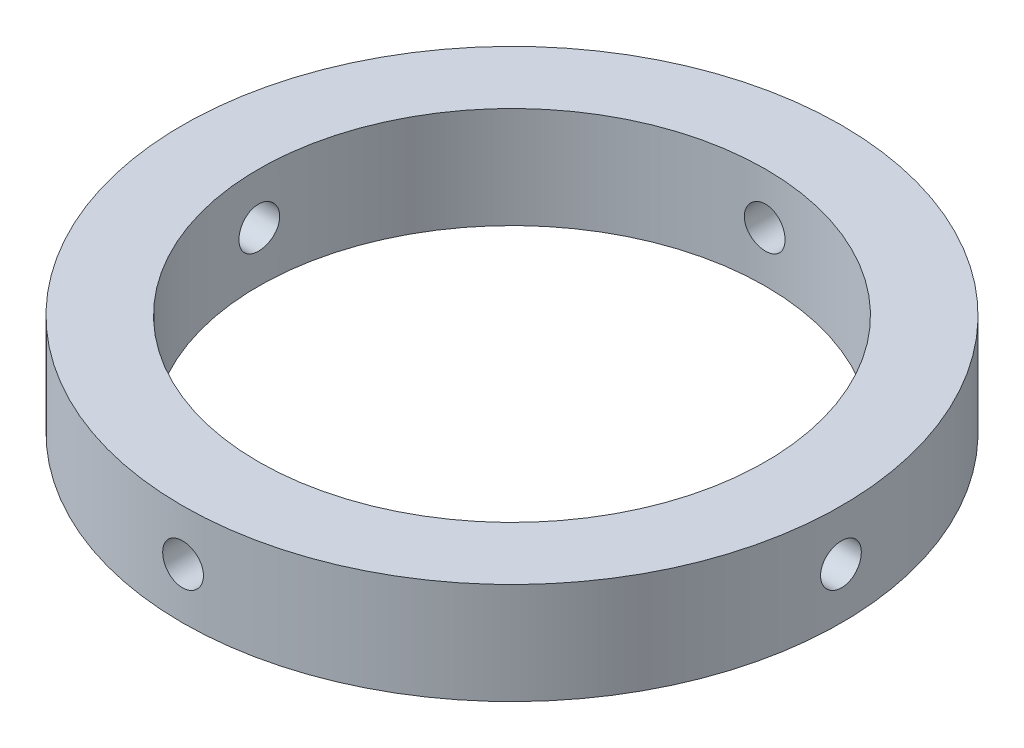
from build123d import *

# Parameters (mm, degrees)
SKETCH1_R           = 41.275
SKETCH1_R_2         = 31.75
BOSS_EXTRUDE1_DEPTH = 12.7
CIRPATTERN1_COUNT   = 4


with BuildPart() as part:
    # Sketch1 → Boss-Extrude1 (new body)
    with BuildSketch(Plane(origin=(0, 0, 0), x_dir=(1, 0, 0), z_dir=(0, 1, 0))):
        Circle(SKETCH1_R)
        Circle(SKETCH1_R_2, mode=Mode.SUBTRACT)
    extrude(amount=BOSS_EXTRUDE1_DEPTH)

    # Sketch3 → 7 _0.201_ Diameter Hole1 (revolve, cut)
    with BuildSketch(Plane(origin=(0, 6.35, 41.275), x_dir=(0, -1, 0), z_dir=(1, 0, 0))):
        Polygon((0, 0), (0, 13.217816902), (2.5527, 11.684), (2.5527, 0), align=None)
    f_7_0_201_diameter_hole1 = revolve(axis=Axis((0, 6.35, 47.625), (0, 0, -1)), mode=Mode.SUBTRACT)

    # CirPattern1: 7 _0.201_ Diameter Hole1 ×4 about axis
    cirpattern1_axis = Axis((0, -0.3175, 0), (0, 1, 0))
    for i in range(1, CIRPATTERN1_COUNT):
        add(f_7_0_201_diameter_hole1.rotate(cirpattern1_axis, i * 360 / CIRPATTERN1_COUNT), mode=Mode.SUBTRACT)


solid = part.part
